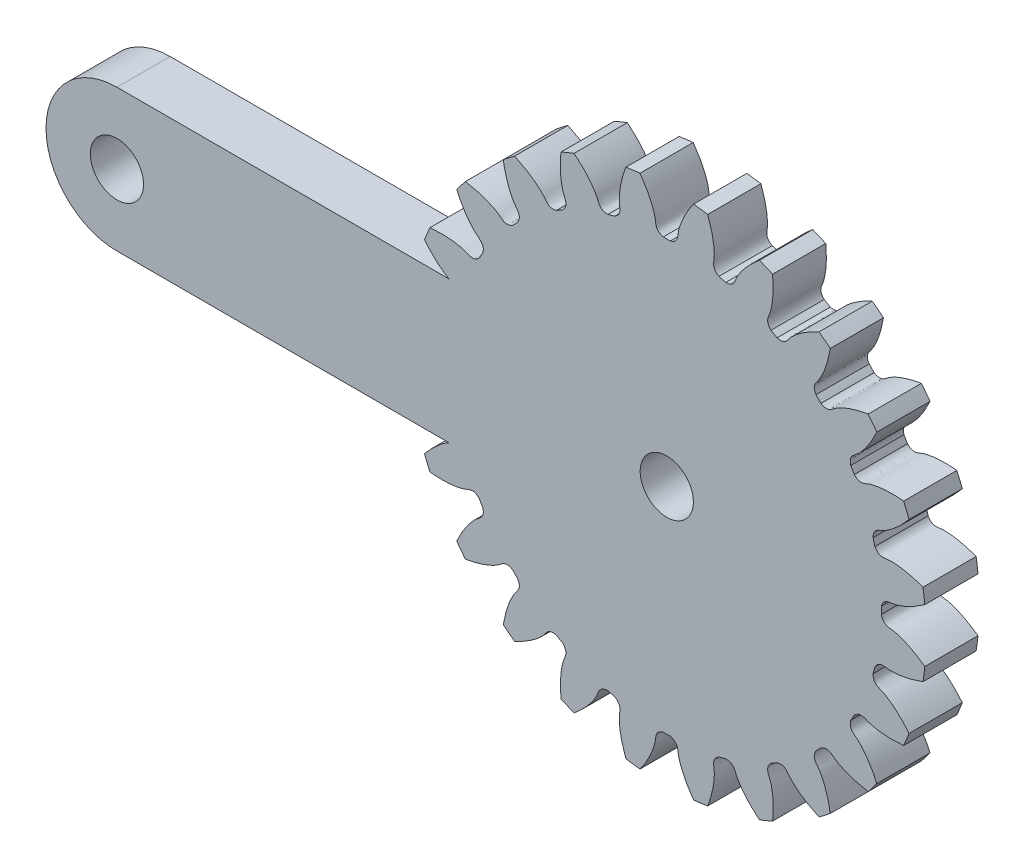
from build123d import *

# Parameters (mm, degrees)
SKETCH_1_R               = 14.625
EXTRUDE_1_DEPTH          = 3
CUT_EXTRUDE_1_DEPTH      = 21.89931219
PATTERN_CIRCULAR_1_COUNT = 24
SKETCH_4_R               = 1.5
EXTRUDE_2_DEPTH          = 3
SKETCH_6_R               = 1.5
CUT_EXTRUDE_3_DEPTH      = 3


with BuildPart() as part:
    # 草图1 → 凸台-拉伸1 (new body)
    with BuildSketch(Plane.XY):
        Circle(SKETCH_1_R)
    extrude(amount=EXTRUDE_1_DEPTH)

    # 草图2 → 切除-拉伸1 (cut, through all)
    with BuildSketch(Plane.XY):
        with BuildLine():
            ThreePointArc((0.198935901, 12.092113693), (0, 12.09375), (-0.198935901, 12.092113693))
            add(Edge.make_bspline(
                [(-0.198935901, 12.092113693), (-0.638901243, 12.213967581), (-0.606428737, 12.505189047), (-0.659561824, 12.794270009), (-0.667165407, 12.831562173), (-0.676629544, 12.873645163), (-0.688140684, 12.920459304), (-0.701893839, 12.971937007), (-0.718078836, 13.028005542), (-0.736884474, 13.088586227), (-0.758497025, 13.153594749), (-0.783100493, 13.222941139), (-0.810876339, 13.296529861), (-0.842003373, 13.374259864), (-0.876657588, 13.456024661), (-0.915012025, 13.541712397), (-0.957236622, 13.631205923), (-1.003498077, 13.724382883), (-1.053959703, 13.821115791), (-1.108781295, 13.921272121), (-1.16811899, 14.024714397), (-1.232125134, 14.131300287), (-1.300948154, 14.240882702), (-1.374732426, 14.353309893), (-1.453618147, 14.468425557), (-1.537741214, 14.586068945), (-1.627233103, 14.706074971), (-1.722220748, 14.828274324), (-1.822826426, 14.952493587), (-1.929167644, 15.078555355), (-2.041357031, 15.206278354), (-2.159502227, 15.335477573), (-2.283705781, 15.465964384), (-2.414065051, 15.597546676), (-2.550672105, 15.730028987), (-2.693613624, 15.863212642), (-2.842970824, 15.996895886), (-2.998819321, 16.130874027), (-3.217974855, 16.311781751), (-3.388414281, 16.443988108), (-3.50507196, 16.53088267)],
                knots=[0, 0, 0, 0, 0.143961355, 0.149818462, 0.156576662, 0.164235955, 0.172796342, 0.182257821, 0.192620395, 0.203884061, 0.216048821, 0.229114674, 0.24308162, 0.25794966, 0.273718793, 0.290389019, 0.307960339, 0.326432751, 0.345806258, 0.366080857, 0.38725655, 0.409333336, 0.432311215, 0.456190188, 0.480970254, 0.506651413, 0.533233666, 0.560717012, 0.589101451, 0.618386984, 0.64857361, 0.679661329, 0.711650141, 0.744540047, 0.778331046, 0.813023138, 0.848616324, 0.885110603, 0.922505975, 1, 1, 1, 1], degree=3))
            ThreePointArc((-3.50507196, 16.53088267), (0, 16.89839079), (3.50507196, 16.53088267))
            add(Edge.make_bspline(
                [(0.198935901, 12.092113693), (0.638901243, 12.213967581), (0.606428737, 12.505189047), (0.659561824, 12.794270009), (0.667165407, 12.831562173), (0.676629544, 12.873645163), (0.688140684, 12.920459304), (0.701893839, 12.971937007), (0.718078836, 13.028005542), (0.736884474, 13.088586227), (0.758497025, 13.153594749), (0.783100493, 13.222941139), (0.810876339, 13.296529861), (0.842003373, 13.374259864), (0.876657588, 13.456024661), (0.915012025, 13.541712397), (0.957236622, 13.631205923), (1.003498077, 13.724382883), (1.053959703, 13.821115791), (1.108781295, 13.921272121), (1.16811899, 14.024714397), (1.232125134, 14.131300287), (1.300948154, 14.240882702), (1.374732426, 14.353309893), (1.453618147, 14.468425557), (1.537741214, 14.586068945), (1.627233103, 14.706074971), (1.722220748, 14.828274324), (1.822826426, 14.952493587), (1.929167644, 15.078555355), (2.041357031, 15.206278354), (2.159502227, 15.335477573), (2.283705781, 15.465964384), (2.414065051, 15.597546676), (2.550672105, 15.730028987), (2.693613624, 15.863212642), (2.842970824, 15.996895886), (2.998819321, 16.130874027), (3.217974855, 16.311781751), (3.388414281, 16.443988108), (3.50507196, 16.53088267)],
                knots=[0, 0, 0, 0, 0.143961355, 0.149818462, 0.156576662, 0.164235955, 0.172796342, 0.182257821, 0.192620395, 0.203884061, 0.216048821, 0.229114674, 0.24308162, 0.25794966, 0.273718793, 0.290389019, 0.307960339, 0.326432751, 0.345806258, 0.366080857, 0.38725655, 0.409333336, 0.432311215, 0.456190188, 0.480970254, 0.506651413, 0.533233666, 0.560717012, 0.589101451, 0.618386984, 0.64857361, 0.679661329, 0.711650141, 0.744540047, 0.778331046, 0.813023138, 0.848616324, 0.885110603, 0.922505975, 1, 1, 1, 1], degree=3))
        make_face()
    cut_extrude_1 = extrude(amount=CUT_EXTRUDE_1_DEPTH, mode=Mode.SUBTRACT)

    # 阵列(圆周)1: 切除-拉伸1 ×24 about axis
    pattern_circular_1_axis = Axis((0, 0, -1.5), (0, 0, 1))
    for i in range(1, PATTERN_CIRCULAR_1_COUNT):
        add(cut_extrude_1.rotate(pattern_circular_1_axis, i * 360 / PATTERN_CIRCULAR_1_COUNT), mode=Mode.SUBTRACT)

    # 草图4 → 凸台-拉伸2 (add)
    with BuildSketch(Plane.XY.offset(3)):
        with BuildLine():
            Line((0, -4), (-31, -4))
            ThreePointArc((-31, -4), (-35, 0), (-31, 4))
            Line((-31, 4), (0, 4))
            ThreePointArc((0, 4), (4, 0), (0, -4))
        make_face()
        with Locations((-31, 0)):
            Circle(SKETCH_4_R, mode=Mode.SUBTRACT)
    extrude(amount=-EXTRUDE_2_DEPTH)

    # 草图6 → 切除-拉伸3 (cut)
    with BuildSketch(Plane.XY.offset(3)):
        Circle(SKETCH_6_R)
    extrude(amount=-CUT_EXTRUDE_3_DEPTH, mode=Mode.SUBTRACT)


solid = part.part
